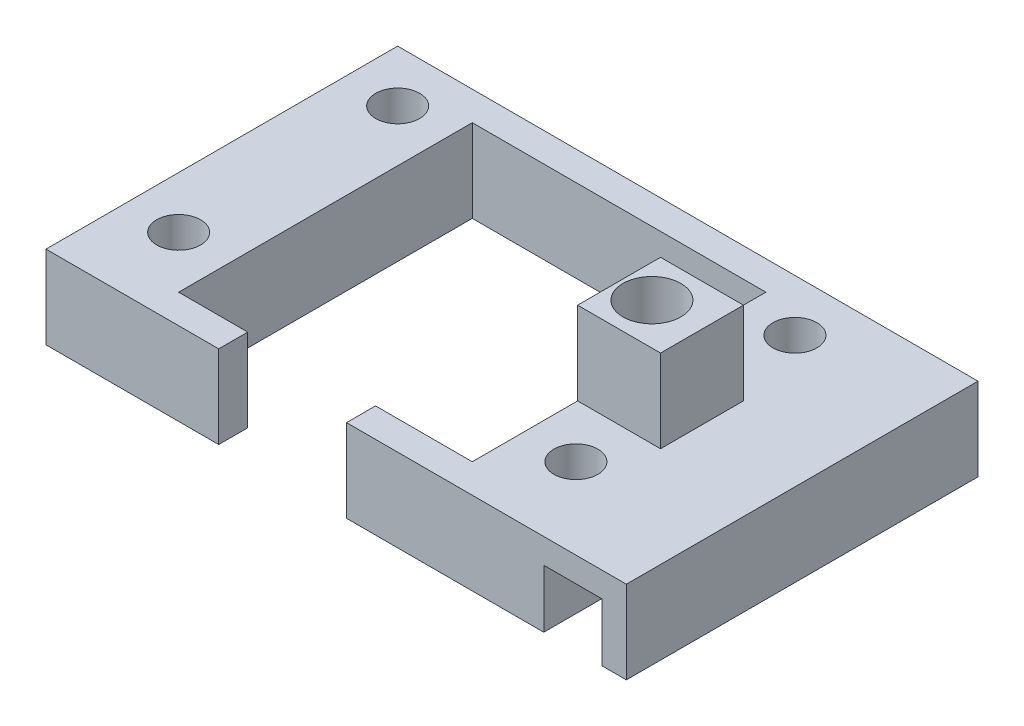
from build123d import *

# Parameters (mm, degrees)
SKETCH1_R           = 3.175
BOSS_EXTRUDE1_DEPTH = 12
BOSS_EXTRUDE2_DEPTH = 50.9
SKETCH5_W           = 12
SKETCH5_H           = 12
SKETCH5_R           = 4.2
BOSS_EXTRUDE3_DEPTH = 12


with BuildPart() as part:
    # Sketch1 → Boss-Extrude1 (new body)
    with BuildSketch(Plane(origin=(0, 0, 0), x_dir=(1, 0, 0), z_dir=(0, 1, 0))):
        Polygon((-15, 0), (0, 0), (0, 42.5), (42.5, 42.5), (42.5, 0), (53.5, 0), (53.5, 46.7), (-15, 46.7), align=None)
        with Locations((-7.5, 7.5)):
            Circle(SKETCH1_R, mode=Mode.SUBTRACT)
        with Locations((50, 7.5)):
            Circle(SKETCH1_R, mode=Mode.SUBTRACT)
        with Locations((-7.5, 39.2)):
            Circle(SKETCH1_R, mode=Mode.SUBTRACT)
        with Locations((50, 39.2)):
            Circle(SKETCH1_R, mode=Mode.SUBTRACT)
        Polygon((10, 0), (0, 0), (-15, 0), (-15, -4.2), (10, -4.2), align=None)
        Polygon((42.5, 0), (28.5, 0), (28.5, -4.2), (53.5, -4.2), (53.5, 0), align=None)
    extrude(amount=BOSS_EXTRUDE1_DEPTH)

    # Sketch4 → Boss-Extrude2 (add)
    with BuildSketch(Plane(origin=(53.3, 0, 4.2), x_dir=(-1, 0, 0), z_dir=(0, 0, -1))):
        Polygon((-15.7, 12), (-15.7, 0), (-12.15, 0), (-12.15, 8.4), (-3.75, 8.4), (-3.75, 0), (-0.2, 0), (-0.2, 12), align=None)
    extrude(amount=BOSS_EXTRUDE2_DEPTH)

    # Sketch5 → Boss-Extrude3 (add)
    with BuildSketch(Plane(origin=(0, 12, 0), x_dir=(1, 0, 0), z_dir=(0, 1, 0))):
        with Locations((48.5, 21.25)):
            Rectangle(SKETCH5_W, SKETCH5_H)
        with Locations((47.25, 21.25)):
            Circle(SKETCH5_R, mode=Mode.SUBTRACT)
    extrude(amount=BOSS_EXTRUDE3_DEPTH)


solid = part.part
